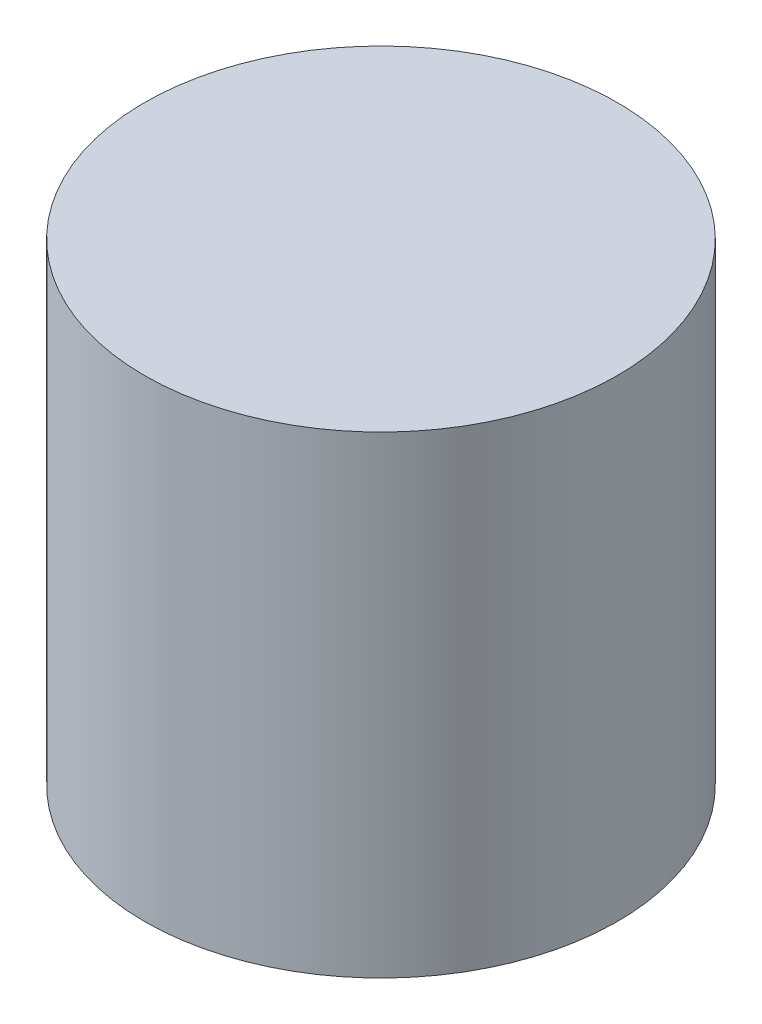
from build123d import *

# Parameters (mm, degrees)
SKETCH_1_R      = 20
EXTRUDE_1_DEPTH = 40


with BuildPart() as part:
    # 草图1 → 凸台-拉伸1 (new body)
    with BuildSketch(Plane(origin=(0, 0, 0), x_dir=(1, 0, 0), z_dir=(0, 1, 0))):
        Circle(SKETCH_1_R)
    extrude(amount=EXTRUDE_1_DEPTH)


solid = part.part
